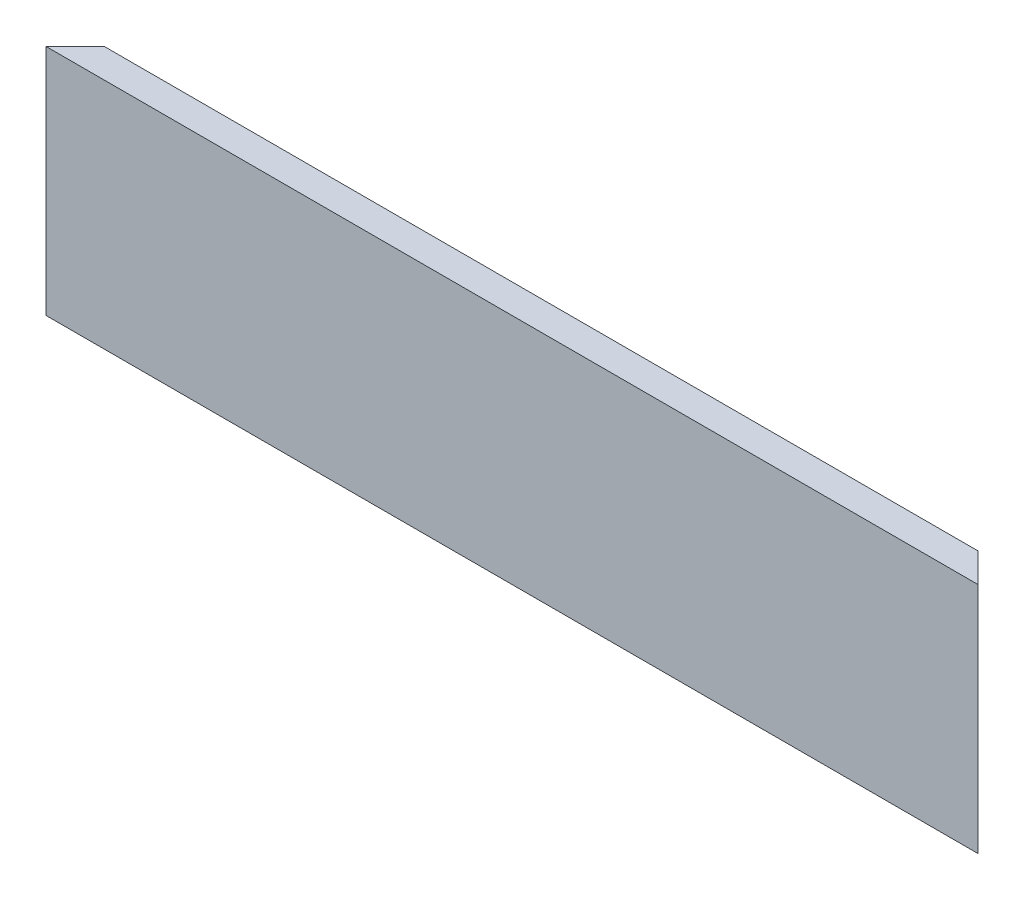
from build123d import *

# Parameters (mm, degrees)
BOSS_EXTRUDE1_DEPTH     = 50.8
CUT_EXTRUDE1_DEPTH      = 26.4
CUT_EXTRUDE1_DEPTH_BACK = 1


with BuildPart() as part:
    # Sketch1 → Boss-Extrude1 (new body, symmetric)
    with BuildSketch(Plane(origin=(0, 0, 0), x_dir=(0, 0, -1), z_dir=(1, 0, 0))):
        Polygon((0, 0), (0, 25.4), (3.175, 25.4), (3.175, 3.175), (25.4, 3.175), (25.4, 0), align=None)
    extrude(amount=BOSS_EXTRUDE1_DEPTH, both=True)

    # Sketch2 → Cut-Extrude1 (cut, two sides)
    with BuildSketch(Plane(origin=(0, 0, 0), x_dir=(1, 0, 0), z_dir=(0, 1, 0))) as cut_extrude1_sk:
        Polygon((-50.8, 0), (-25.4, 25.4), (-50.8, 25.4), align=None)
        Polygon((50.8, 0), (50.8, 25.4), (25.4, 25.4), align=None)
    extrude(amount=CUT_EXTRUDE1_DEPTH, mode=Mode.SUBTRACT)
    extrude(cut_extrude1_sk.sketch, amount=-CUT_EXTRUDE1_DEPTH_BACK, mode=Mode.SUBTRACT)


solid = part.part
